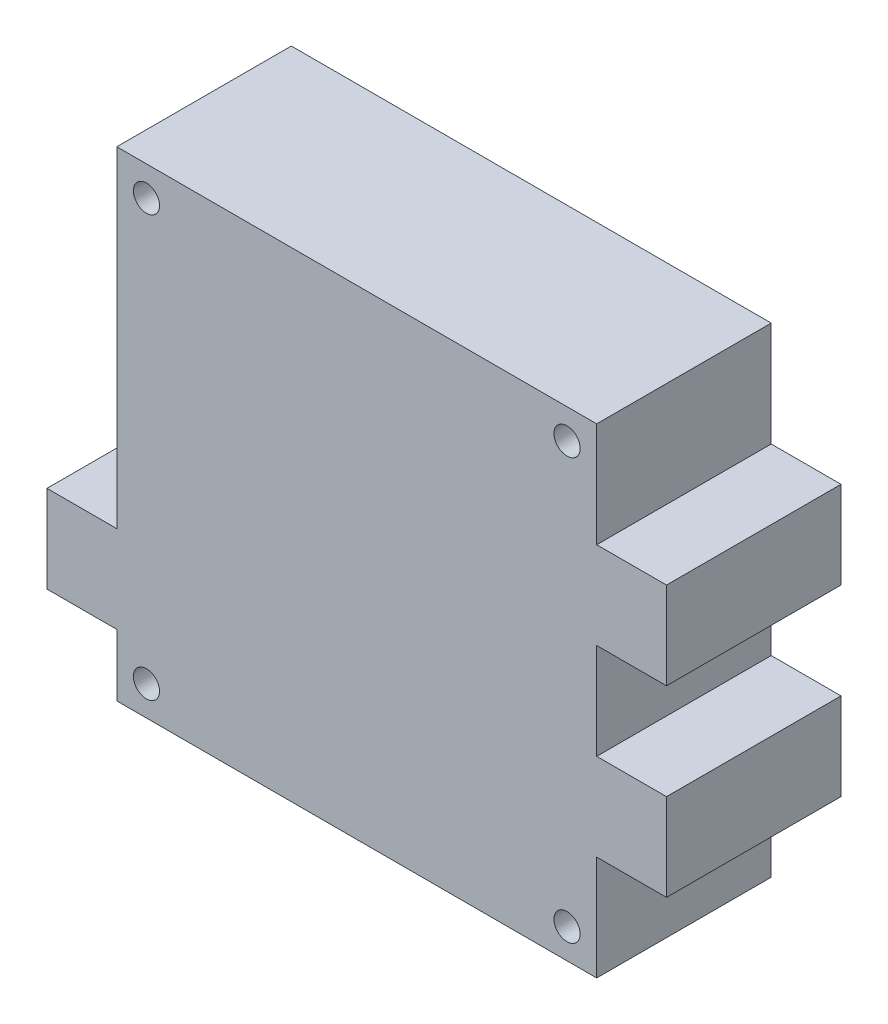
from build123d import *

# Parameters (mm, degrees)
SKETCH_1_R      = 1.5
EXTRUDE_1_DEPTH = 20


with BuildPart() as part:
    # 草图1 → 凸台-拉伸1 (new body)
    with BuildSketch(Plane.XY):
        Polygon((-27.5, -20.402404897), (-35.5, -20.402404897), (-35.5, -10.402404897), (-27.5, -10.402404897), (-27.5, 27.5), (27.5, 27.5), (27.5, 15.5), (35.5, 15.5), (35.5, 5.5), (27.5, 5.5), (27.5, -5.5), (35.5, -5.5), (35.5, -15.5), (27.5, -15.5), (27.5, -27.5), (-27.5, -27.5), align=None)
        with Locations((-24.1, 24.1)):
            Circle(SKETCH_1_R, mode=Mode.SUBTRACT)
        with Locations((24.1, 24.1)):
            Circle(SKETCH_1_R, mode=Mode.SUBTRACT)
        with Locations((-24.1, -24.1)):
            Circle(SKETCH_1_R, mode=Mode.SUBTRACT)
        with Locations((24.1, -24.1)):
            Circle(SKETCH_1_R, mode=Mode.SUBTRACT)
    extrude(amount=EXTRUDE_1_DEPTH)


solid = part.part
